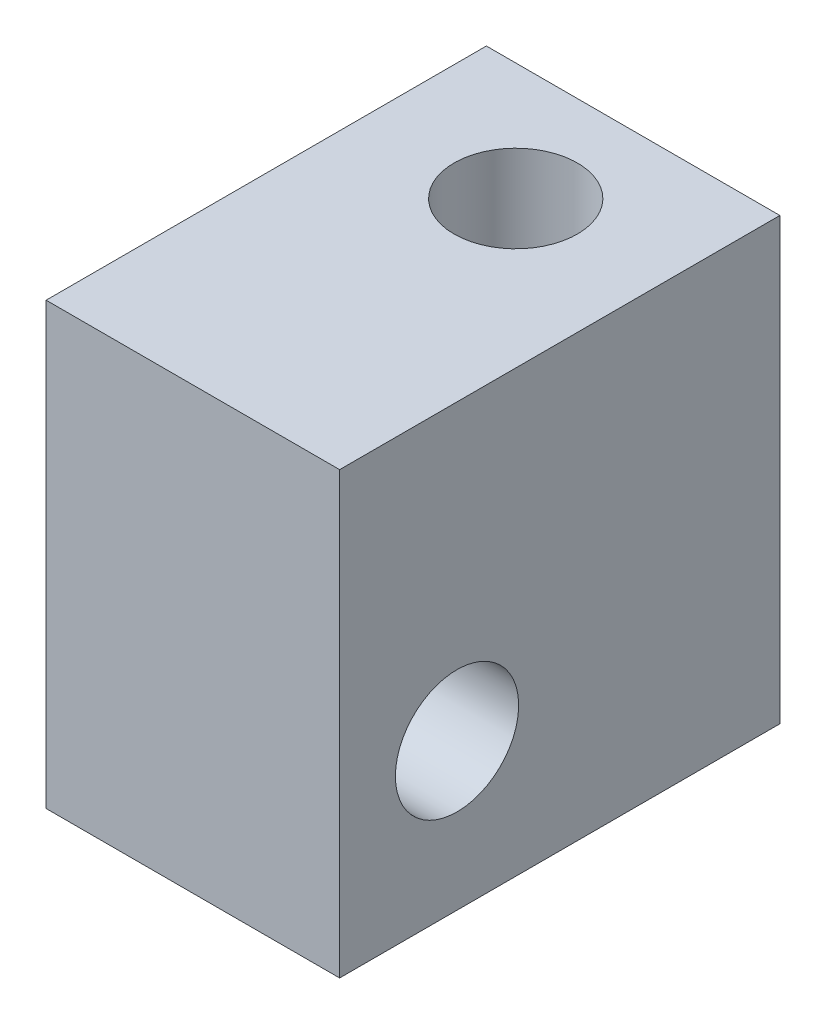
from build123d import *

# Parameters (mm, degrees)
SKETCH1_W             = 10
SKETCH1_H             = 15
BOSS_EXTRUDE1_DEPTH   = 15
M5X0_8_TAPPED_HOLE1_D = 4.2
M5X0_8_TAPPED_HOLE2_D = 4.2


with BuildPart() as part:
    # Sketch1 → Boss-Extrude1 (new body)
    with BuildSketch(Plane.XY):
        Rectangle(SKETCH1_W, SKETCH1_H)
    extrude(amount=BOSS_EXTRUDE1_DEPTH)

    # M5x0.8 Tapped Hole1 (through all)
    with Locations(Plane(origin=(0, 7.5, 0), x_dir=(1, 0, 0), z_dir=(0, 1, 0))):
        with Locations((0, -4)):
            Hole(M5X0_8_TAPPED_HOLE1_D / 2)

    # M5x0.8 Tapped Hole2 (through all)
    with Locations(Plane.ZY.offset(5)):
        with Locations((11, -2.5)):
            Hole(M5X0_8_TAPPED_HOLE2_D / 2)


solid = part.part
